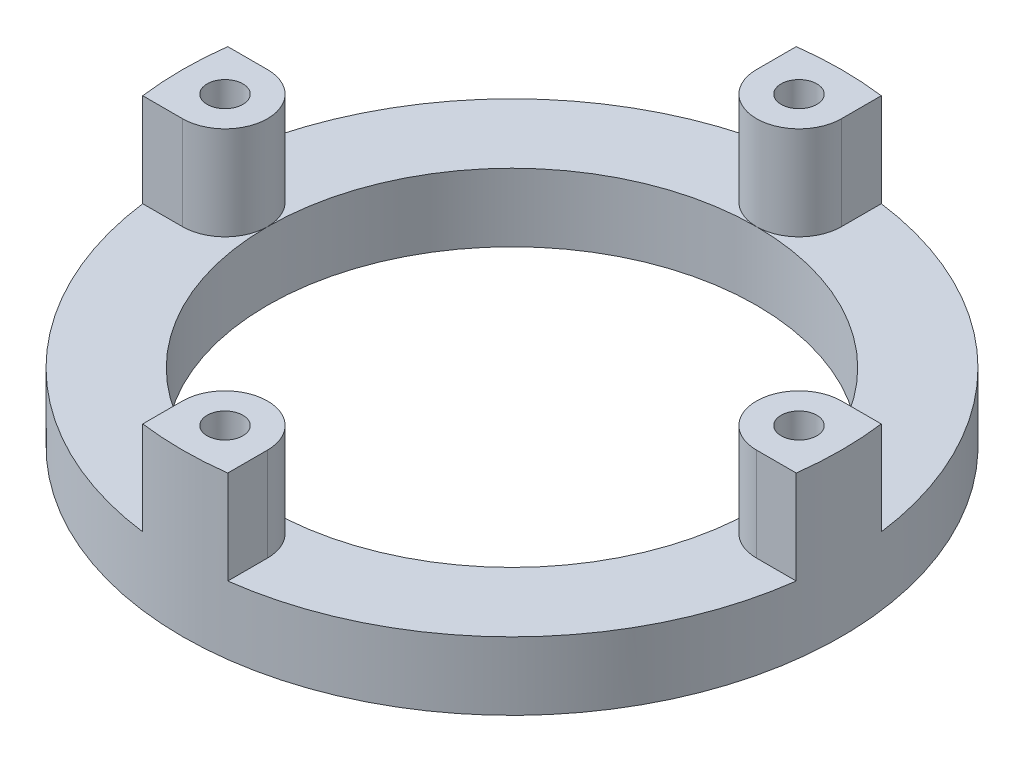
from build123d import *

# Parameters (mm, degrees)
SKETCH1_R           = 98.425
SKETCH1_R_2         = 73.025
BOSS_EXTRUDE1_DEPTH = 20.32
SKETCH9_R           = 5.334
BOSS_EXTRUDE6_DEPTH = 27.94
CIRPATTERN5_COUNT   = 4


with BuildPart() as part:
    # Sketch1 → Boss-Extrude1 (new body)
    with BuildSketch(Plane(origin=(0, 0, 0), x_dir=(1, 0, 0), z_dir=(0, 1, 0))):
        Circle(SKETCH1_R)
        Circle(SKETCH1_R_2, mode=Mode.SUBTRACT)
    extrude(amount=BOSS_EXTRUDE1_DEPTH)

    # Sketch9 → Boss-Extrude6 (add)
    with BuildSketch(Plane(origin=(0, 20.32, 0), x_dir=(1, 0, 0), z_dir=(0, 1, 0))):
        with BuildLine():
            Line((-12.7, 85.725), (-12.7, 97.602206046))
            ThreePointArc((-12.7, 97.602206046), (0, 98.425), (12.7, 97.602206046))
            Line((12.7, 97.602206046), (12.7, 85.725))
            ThreePointArc((12.7, 85.725), (0, 73.025), (-12.7, 85.725))
        make_face()
        with Locations((0, 85.725)):
            Circle(SKETCH9_R, mode=Mode.SUBTRACT)
    boss_extrude6 = extrude(amount=BOSS_EXTRUDE6_DEPTH)

    # CirPattern5: Boss-Extrude6 ×4 about axis
    cirpattern5_axis = Axis((0, 0, 0), (0, 1, 0))
    for i in range(1, CIRPATTERN5_COUNT):
        add(boss_extrude6.rotate(cirpattern5_axis, i * 360 / CIRPATTERN5_COUNT))


solid = part.part
